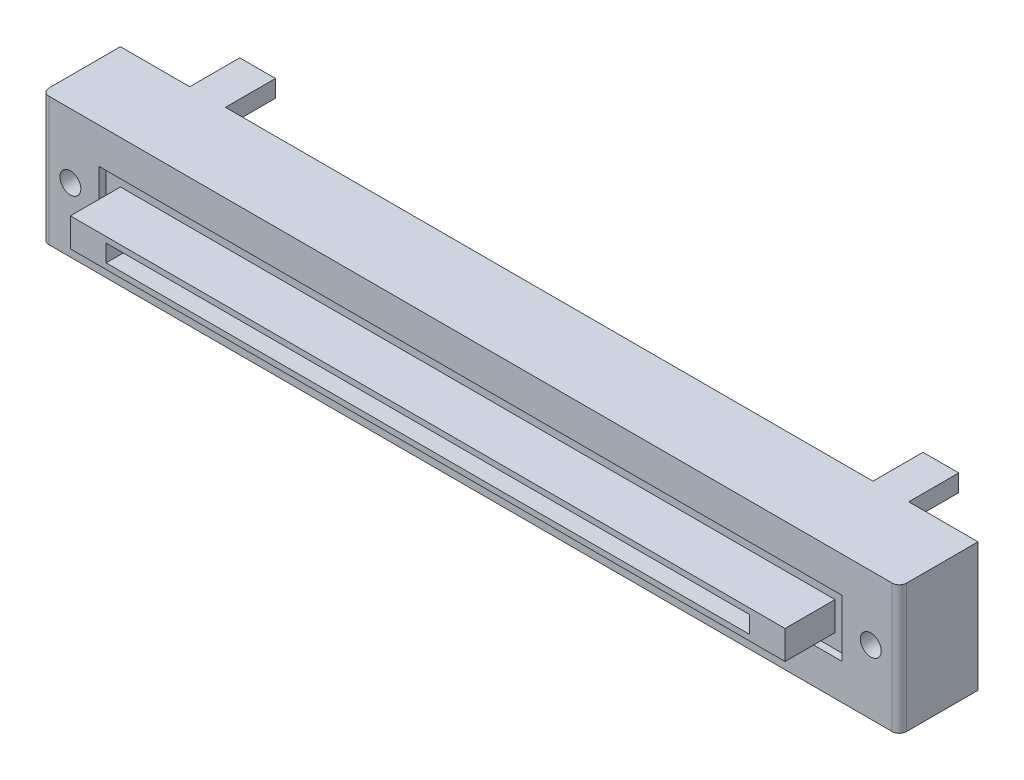
from build123d import *

# Parameters (mm, degrees)
SKIZZE1_W                       = 60
SKIZZE1_H                       = 9
BODY_DEPTH                      = 5.5
SKIZZE4_R                       = 0.730693515
SCREW_HOLES_DEPTH               = 3
SKIZZE5_W                       = 52
SKIZZE5_H                       = 4
SCHNITT_LINEAR_AUSTRAGEN3_DEPTH = 0.5
VERRUNDUNG1_R                   = 0.5
PATHWAY_OF_GLIDER_W             = 50
PATHWAY_OF_GLIDER_H             = 2
PATHWAY_DEPTH                   = 3
SKIZZE7_W                       = 45
SKIZZE7_H                       = 1.2
F_45MM_DEPTH                    = 3
FLAP_W                          = 2.5
FLAP_H                          = 1.2
FLAPS_DEPTH                     = 3.5


with BuildPart() as part:
    # Skizze1 → body (new body)
    with BuildSketch(Plane.XY):
        Rectangle(SKIZZE1_W, SKIZZE1_H)
    extrude(amount=-BODY_DEPTH)

    # Skizze4 → screw holes (cut)
    with BuildSketch(Plane.XY):
        with Locations((-28, 0)):
            Circle(SKIZZE4_R)
        with Locations((28, 0)):
            Circle(SKIZZE4_R)
    extrude(amount=-SCREW_HOLES_DEPTH, mode=Mode.SUBTRACT)

    # Skizze5 → Schnitt-Linear austragen3 (cut)
    with BuildSketch(Plane.XY):
        Rectangle(SKIZZE5_W, SKIZZE5_H)
    extrude(amount=-SCHNITT_LINEAR_AUSTRAGEN3_DEPTH, mode=Mode.SUBTRACT)

    # Verrundung1
    verrundung1_edges = [part.edges().sort_by_distance(p)[0] for p in [
        (-30, 0, 0),
        (30, 0, 0),
    ]]
    fillet(verrundung1_edges, radius=VERRUNDUNG1_R)

    # flap → flaps (add)
    with BuildSketch(Plane(origin=(0, 0, -5.5), x_dir=(-1, 0, 0), z_dir=(0, 0, -1))):
        with Locations((-25.1, -3.9)):
            Rectangle(FLAP_W, FLAP_H)
        with Locations((25.1, -3.9)):
            Rectangle(FLAP_W, FLAP_H)
        with Locations((23.9, 3.9)):
            Rectangle(FLAP_W, FLAP_H)
        with Locations((-23.9, 3.9)):
            Rectangle(FLAP_W, FLAP_H)
    extrude(amount=FLAPS_DEPTH)


with BuildPart() as body_2:
    # pathway of glider → pathway (new body, symmetric)
    with BuildSketch(Plane.XY):
        Rectangle(PATHWAY_OF_GLIDER_W, PATHWAY_OF_GLIDER_H)
    extrude(amount=PATHWAY_DEPTH, both=True)

    # Skizze7 → 45mm (cut)
    with BuildSketch(Plane.XY.offset(3)):
        Rectangle(SKIZZE7_W, SKIZZE7_H)
    extrude(amount=-F_45MM_DEPTH, mode=Mode.SUBTRACT)


solid = Compound([part.part, body_2.part])
